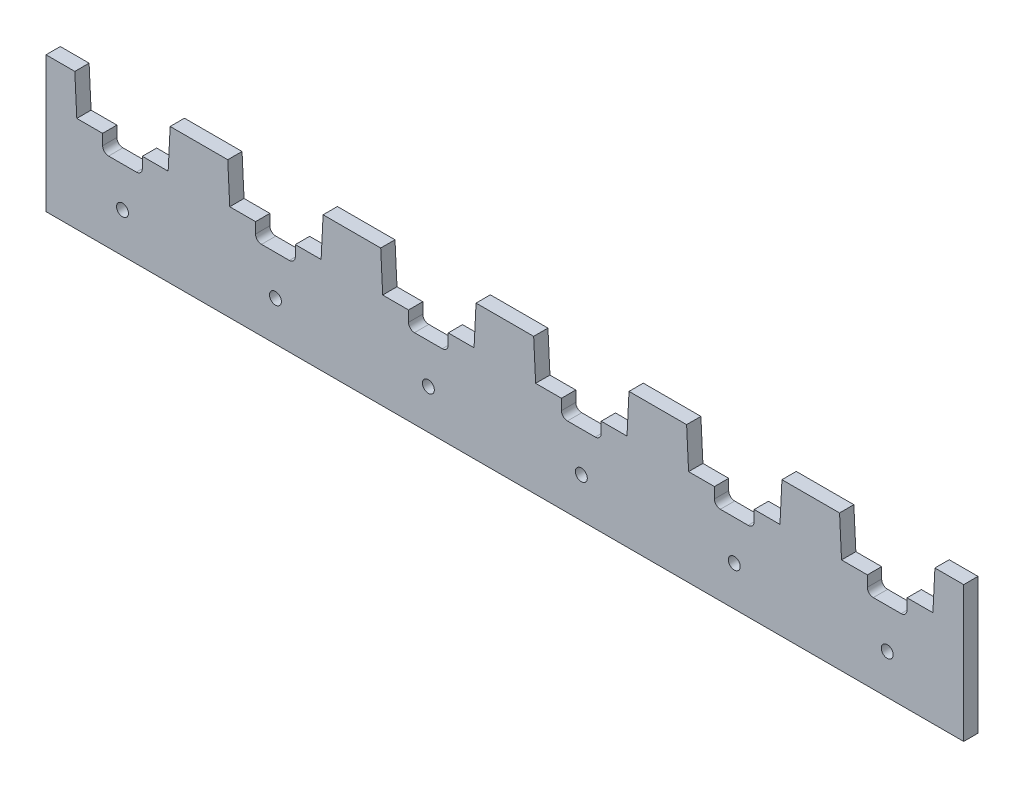
from build123d import *

# Parameters (mm, degrees)
SKETCH1_R              = 1.5
BOSS_EXTRUDE1_DEPTH    = 3.6
FILLET1_R              = 1.5
LPATTERN2_COUNT        = 6
LPATTERN2_PITCH        = 38.5
FILLET1_OF_LPATTERN2_R = 1.5


with BuildPart() as part:
    # Sketch1 → Boss-Extrude1 (new body)
    with BuildSketch(Plane.XY):
        Polygon((-19.25, 14.2), (-19.25, 0), (-19.25, -20), (19.25, -20), (19.25, 0), (19.25, 14.2), (12, 14.2), (11.5, 4.2), (5, 4.2), (5, 0), (-5, 0), (-5, 4.2), (-11.5, 4.2), (-12, 14.2), align=None)
        with Locations((0, -10)):
            Circle(SKETCH1_R, mode=Mode.SUBTRACT)
    boss_extrude1 = extrude(amount=BOSS_EXTRUDE1_DEPTH)

    # Fillet1
    fillet1_edges = [part.edges().sort_by_distance(p)[0] for p in [
        (-5, 0, 1.8),
        (5, 0, 1.8),
    ]]
    fillet(fillet1_edges, radius=FILLET1_R)

    # LPattern2: Boss-Extrude1 ×6
    with Locations(*[(i * LPATTERN2_PITCH, 0, 0) for i in range(1, LPATTERN2_COUNT)]):
        add(boss_extrude1)

    # Fillet1 of LPattern2
    fillet1_of_lpattern2_edges = [part.edges().sort_by_distance(p)[0] for p in [
        (33.5, 0, 1.8),
        (43.5, 0, 1.8),
        (72, 0, 1.8),
        (82, 0, 1.8),
        (110.5, 0, 1.8),
        (120.5, 0, 1.8),
        (149, 0, 1.8),
        (159, 0, 1.8),
        (187.5, 0, 1.8),
        (197.5, 0, 1.8),
    ]]
    fillet(fillet1_of_lpattern2_edges, radius=FILLET1_OF_LPATTERN2_R)


solid = part.part
